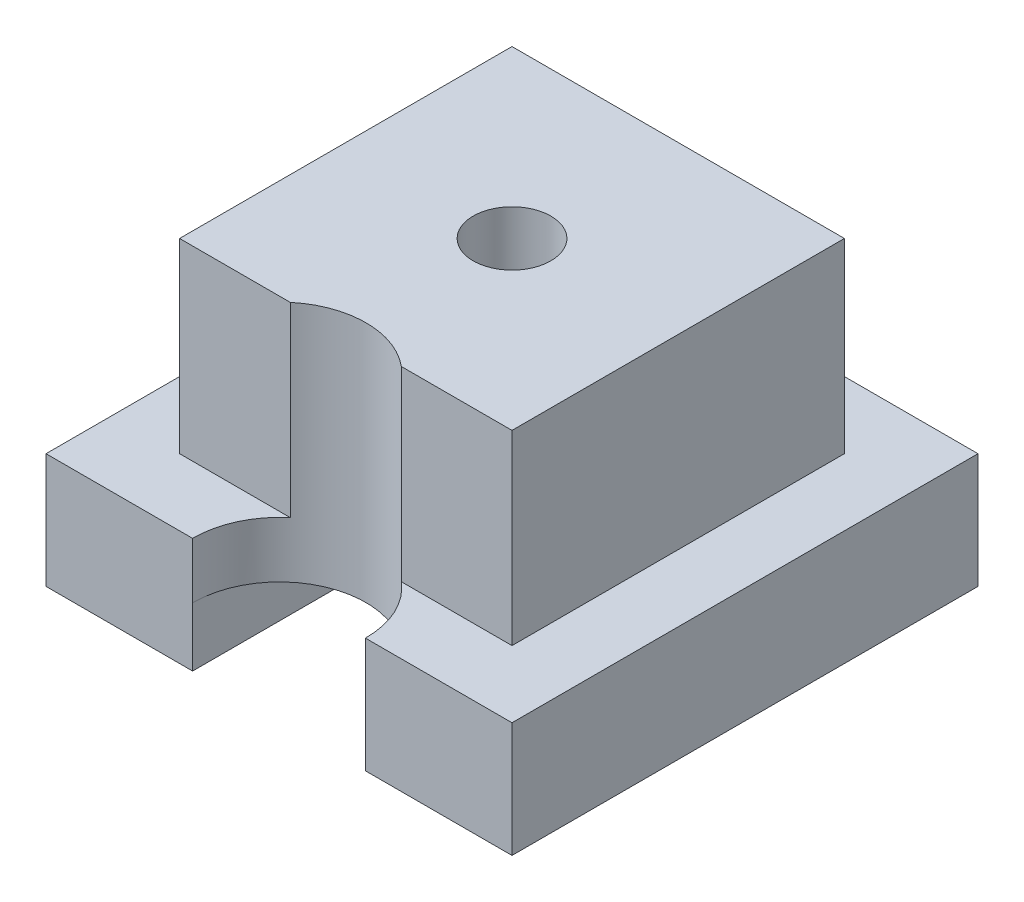
from build123d import *

# Parameters (mm, degrees)
SKETCH1_W               = 38.1
SKETCH1_H               = 38.1
BOSS_EXTRUDE1_DEPTH     = 4.572
SKETCH5_W               = 27.178
SKETCH5_H               = 27.178
BOSS_EXTRUDE2_DEPTH     = 19.812
SKETCH2_R               = 7.06349997
CUT_EXTRUDE1_DEPTH      = 20.812
F_1_4_20_TAPPED_HOLE1_D = 6.35
SKETCH6_W               = 11.986676998
SKETCH6_H               = 38.1
BOSS_EXTRUDE3_DEPTH     = 4.826


with BuildPart() as part:
    # Sketch1 → Boss-Extrude1 (new body)
    with BuildSketch(Plane(origin=(0, 0, 0), x_dir=(1, 0, 0), z_dir=(0, 1, 0))):
        Rectangle(SKETCH1_W, SKETCH1_H)
    extrude(amount=BOSS_EXTRUDE1_DEPTH)

    # Sketch5 → Boss-Extrude2 (add)
    with BuildSketch(Plane(origin=(0, 0, 0), x_dir=(1, 0, 0), z_dir=(0, 1, 0))):
        Rectangle(SKETCH5_W, SKETCH5_H)
    extrude(amount=BOSS_EXTRUDE2_DEPTH)

    # Sketch2 → Cut-Extrude1 (cut, through all)
    with BuildSketch(Plane.XZ):
        with Locations((0, 19)):
            Circle(SKETCH2_R)
    extrude(amount=-CUT_EXTRUDE1_DEPTH, mode=Mode.SUBTRACT)

    # 1/4-20 Tapped Hole1 (through all)
    with Locations(Plane(origin=(0, 0, 0), x_dir=(-1, 0, 0), z_dir=(0, -1, 0))):
        with Locations((0, 0)):
            Hole(F_1_4_20_TAPPED_HOLE1_D / 2)

    # Sketch6 → Boss-Extrude3 (add)
    with BuildSketch(Plane.XZ):
        with Locations((13.056661501, 0)):
            Rectangle(SKETCH6_W, SKETCH6_H)
        with Locations((-13.056661501, 0)):
            Rectangle(SKETCH6_W, SKETCH6_H)
    extrude(amount=BOSS_EXTRUDE3_DEPTH)


solid = part.part
